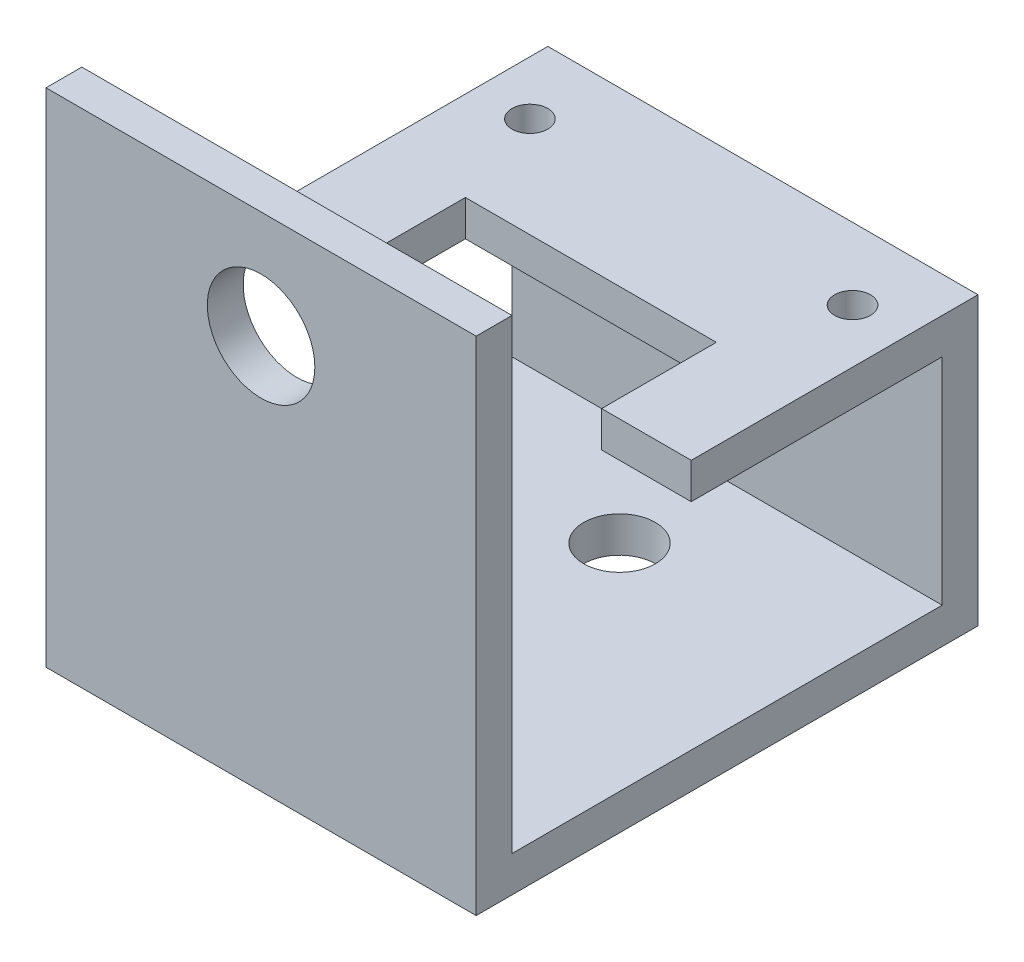
from build123d import *

# Parameters (mm, degrees)
BOSS_EXTRUDE1_DEPTH              = 38.1
SKETCH2_W                        = 22.225
SKETCH2_H                        = 10.16
CUT_EXTRUDE1_DEPTH               = 3.175
SKETCH6_R                        = 1.5875
CUT_EXTRUDE2_DEPTH               = 3.175
SKETCH7_R                        = 4.7625
CUT_EXTRUDE3_DEPTH               = 3.175
F_1_4_0_25_DIAMETER_HOLE1_REACH  = 73.631
F_1_4_0_25_DIAMETER_HOLE1_BORE_R = 3.175


with BuildPart() as part:
    # Sketch1 → Boss-Extrude1 (new body)
    with BuildSketch(Plane(origin=(0, 0, 0), x_dir=(0, 0, -1), z_dir=(1, 0, 0))):
        Polygon((0, 0), (-38.1, 0), (-38.1, 41.275), (-41.275, 41.275), (-41.275, -3.175), (3.175, -3.175), (3.175, 22.225), (-22.225, 22.225), (-22.225, 19.05), (0, 19.05), align=None)
    extrude(amount=BOSS_EXTRUDE1_DEPTH)

    # Sketch2 → Cut-Extrude1 (cut)
    with BuildSketch(Plane(origin=(0, 22.225, 0), x_dir=(1, 0, 0), z_dir=(0, 1, 0))):
        with Locations((19.05, -17.145)):
            Rectangle(SKETCH2_W, SKETCH2_H)
    extrude(amount=-CUT_EXTRUDE1_DEPTH, mode=Mode.SUBTRACT)

    # Sketch6 → Cut-Extrude2 (cut)
    with BuildSketch(Plane(origin=(0, 22.225, 0), x_dir=(1, 0, 0), z_dir=(0, 1, 0))):
        with Locations(Location((33.3375, -3.175, 0), (0, 0, 270))):
            Circle(SKETCH6_R)
        with Locations(Location((4.7625, -3.175, 0), (0, 0, 270))):
            Circle(SKETCH6_R)
    extrude(amount=-CUT_EXTRUDE2_DEPTH, mode=Mode.SUBTRACT)

    # Sketch7 → Cut-Extrude3 (cut)
    with BuildSketch(Plane.XY.offset(41.275)):
        with Locations((19.05, 31.75)):
            Circle(SKETCH7_R)
    extrude(amount=-CUT_EXTRUDE3_DEPTH, mode=Mode.SUBTRACT)

    # 1/4 (0.25) Diameter Hole1 bore → 1/4 (0.25) Diameter Hole1 (cut, up to next)
    with BuildSketch(Plane(origin=(0, -3.175, 0), x_dir=(-1, 0, 0), z_dir=(0, -1, 0)), mode=Mode.PRIVATE) as f_1_4_0_25_diameter_hole1_sk1:
        with Locations((-19.05, -28.575)):
            Circle(F_1_4_0_25_DIAMETER_HOLE1_BORE_R)
    f_1_4_0_25_diameter_hole1_tool1 = extrude(f_1_4_0_25_diameter_hole1_sk1.sketch, amount=-F_1_4_0_25_DIAMETER_HOLE1_REACH, mode=Mode.PRIVATE) & part.part
    # 1/4 (0.25) Diameter Hole1 bore → 1/4 (0.25) Diameter Hole1 (cut, up to next)
    with BuildSketch(Plane(origin=(0, -3.175, 0), x_dir=(-1, 0, 0), z_dir=(0, -1, 0)), mode=Mode.PRIVATE) as f_1_4_0_25_diameter_hole1_sk2:
        with Locations((-19.05, -9.525)):
            Circle(F_1_4_0_25_DIAMETER_HOLE1_BORE_R)
    f_1_4_0_25_diameter_hole1_tool2 = extrude(f_1_4_0_25_diameter_hole1_sk2.sketch, amount=-F_1_4_0_25_DIAMETER_HOLE1_REACH, mode=Mode.PRIVATE) & part.part
    add(f_1_4_0_25_diameter_hole1_tool1.solids().sort_by_distance((19.05, -3.175, 28.575))[0], mode=Mode.SUBTRACT)
    add(f_1_4_0_25_diameter_hole1_tool2.solids().sort_by_distance((19.05, -3.175, 9.525))[0], mode=Mode.SUBTRACT)


solid = part.part
